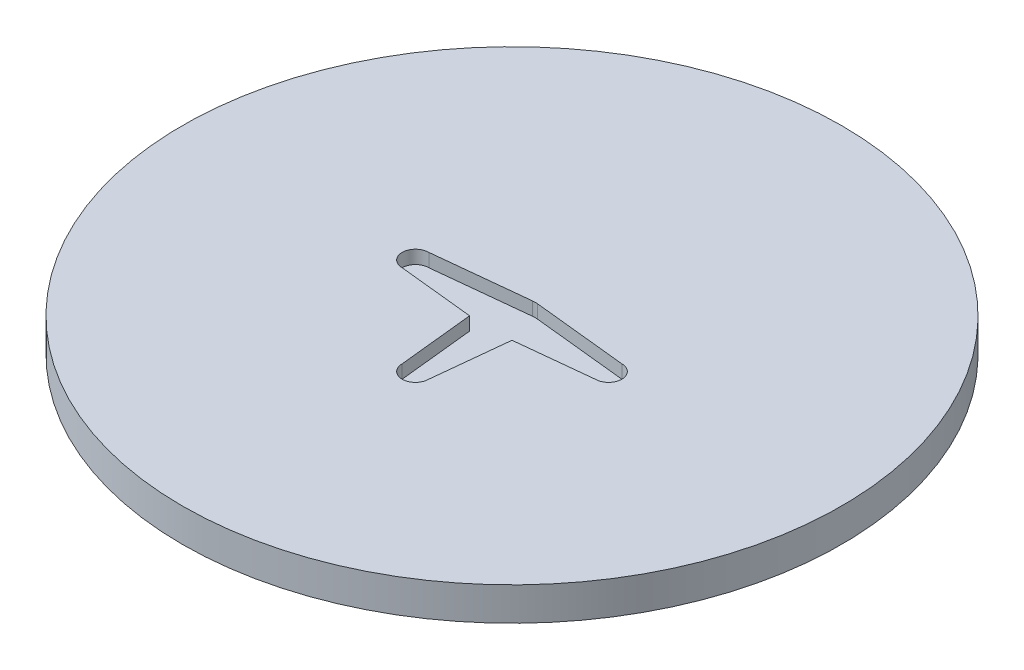
from build123d import *

# Parameters (mm, degrees)
SKETCH1_R           = 49.5
BOSS_EXTRUDE1_DEPTH = 5
CUT_EXTRUDE1_DEPTH  = 2
CUT_EXTRUDE3_DEPTH  = 2.5
CUT_EXTRUDE4_DEPTH  = 1.5
SKETCH5_R           = 2.5
BOSS_EXTRUDE2_DEPTH = 2.5


with BuildPart() as part:
    # Sketch1 → Boss-Extrude1 (new body)
    with BuildSketch(Plane(origin=(0, 0, 0), x_dir=(1, 0, 0), z_dir=(0, 1, 0))):
        Circle(SKETCH1_R)
    extrude(amount=BOSS_EXTRUDE1_DEPTH)

    # Sketch2 → Cut-Extrude1 (cut)
    with BuildSketch(Plane(origin=(0, 5, 0), x_dir=(1, 0, 0), z_dir=(0, 1, 0))):
        with BuildLine():
            Line((14.5, 2), (0.364696883, 3.480947599))
            ThreePointArc((0.364696883, 3.480947599), (0, 3.5), (-0.364696883, 3.480947599))
            Line((-0.364696883, 3.480947599), (-14.5, 2))
            ThreePointArc((-14.5, 2), (-16.5, 0), (-14.5, -2))
            Line((-14.5, -2), (-3.185421861, -3.185421861))
            Line((-3.185421861, -3.185421861), (-2, -14.5))
            ThreePointArc((-2, -14.5), (0, -16.5), (2, -14.5))
            Line((2, -14.5), (3.185421861, -3.185421861))
            Line((3.185421861, -3.185421861), (14.5, -2))
            ThreePointArc((14.5, -2), (16.5, 0), (14.5, 2))
        make_face()
    extrude(amount=-CUT_EXTRUDE1_DEPTH, mode=Mode.SUBTRACT)

    # Sketch3 → Cut-Extrude3 (cut)
    with BuildSketch(Plane.XZ):
        with BuildLine():
            add(Edge.make_bspline(
                [(7.183697139, 7.183697139), (0, 87.002554241), (-7.183697139, 7.183697139)],
                knots=[1.862253121, 1.862253121, 1.862253121, 4.420932186, 4.420932186, 4.420932186], degree=2, weights=[1, 0.287347886, 1]))
            add(Edge.make_bspline(
                [(-7.183697139, 7.183697139), (-87.002554241, 0), (-7.183697139, -7.183697139)],
                knots=[5.003845775, 5.003845775, 5.003845775, 7.562524839, 7.562524839, 7.562524839], degree=2, weights=[1, 0.287347886, 1]))
            add(Edge.make_bspline(
                [(-7.183697139, -7.183697139), (0, -87.002554241), (7.183697139, -7.183697139)],
                knots=[5.003845775, 5.003845775, 5.003845775, 7.562524839, 7.562524839, 7.562524839], degree=2, weights=[1, 0.287347886, 1]))
            add(Edge.make_bspline(
                [(7.183697139, -7.183697139), (87.002554241, 0), (7.183697139, 7.183697139)],
                knots=[1.862253121, 1.862253121, 1.862253121, 4.420932186, 4.420932186, 4.420932186], degree=2, weights=[1, 0.287347886, 1]))
        make_face()
    extrude(amount=-CUT_EXTRUDE3_DEPTH, mode=Mode.SUBTRACT)

    # Sketch4 → Cut-Extrude4 (cut)
    with BuildSketch(Plane.XZ.offset(-2.5)):
        with BuildLine():
            ThreePointArc((25, 0), (23.096988313, 9.567085809), (17.67766953, 17.67766953))
            add(Edge.make_bspline(
                [(17.67766953, 17.67766953), (14.970514542, 20.384824518), (6.074201923, 14.664420662)],
                knots=[3.141592654, 3.141592654, 3.141592654, 4.085563337, 4.085563337, 4.085563337], degree=2, weights=[1, 0.890667398, 1]))
            add(Edge.make_bspline(
                [(6.074201923, 14.664420662), (3.8284953, 25), (0, 25)],
                knots=[2.19762197, 2.19762197, 2.19762197, 3.141592654, 3.141592654, 3.141592654], degree=2, weights=[1, 0.890667398, 1]))
            ThreePointArc((0, 25), (-9.567085809, 23.096988313), (-17.67766953, 17.67766953))
            add(Edge.make_bspline(
                [(-17.67766953, 17.67766953), (-20.384824518, 14.970514542), (-14.664420662, 6.074201923)],
                knots=[0, 0, 0, 0.943970683, 0.943970683, 0.943970683], degree=2, weights=[1, 0.890667398, 1]))
            add(Edge.make_bspline(
                [(-14.664420662, 6.074201923), (-25, 3.8284953), (-25, 0)],
                knots=[5.339214624, 5.339214624, 5.339214624, 6.283185307, 6.283185307, 6.283185307], degree=2, weights=[1, 0.890667398, 1]))
            ThreePointArc((-25, 0), (-23.096988313, -9.567085809), (-17.67766953, -17.67766953))
            add(Edge.make_bspline(
                [(-17.67766953, -17.67766953), (-14.970514542, -20.384824518), (-6.074201923, -14.664420662)],
                knots=[0, 0, 0, 0.943970683, 0.943970683, 0.943970683], degree=2, weights=[1, 0.890667398, 1]))
            add(Edge.make_bspline(
                [(-6.074201923, -14.664420662), (-3.8284953, -25), (0, -25)],
                knots=[5.339214624, 5.339214624, 5.339214624, 6.283185307, 6.283185307, 6.283185307], degree=2, weights=[1, 0.890667398, 1]))
            ThreePointArc((0, -25), (9.567085809, -23.096988313), (17.67766953, -17.67766953))
            add(Edge.make_bspline(
                [(17.67766953, -17.67766953), (20.384824518, -14.970514542), (14.664420662, -6.074201923)],
                knots=[3.141592654, 3.141592654, 3.141592654, 4.085563337, 4.085563337, 4.085563337], degree=2, weights=[1, 0.890667398, 1]))
            add(Edge.make_bspline(
                [(14.664420662, -6.074201923), (25, -3.8284953), (25, 0)],
                knots=[2.19762197, 2.19762197, 2.19762197, 3.141592654, 3.141592654, 3.141592654], degree=2, weights=[1, 0.890667398, 1]))
        make_face()
    extrude(amount=CUT_EXTRUDE4_DEPTH, mode=Mode.SUBTRACT)

    # Sketch5 → Boss-Extrude2 (add)
    with BuildSketch(Plane.XZ.offset(-2.5)):
        Circle(SKETCH5_R)
    extrude(amount=BOSS_EXTRUDE2_DEPTH)


solid = part.part
